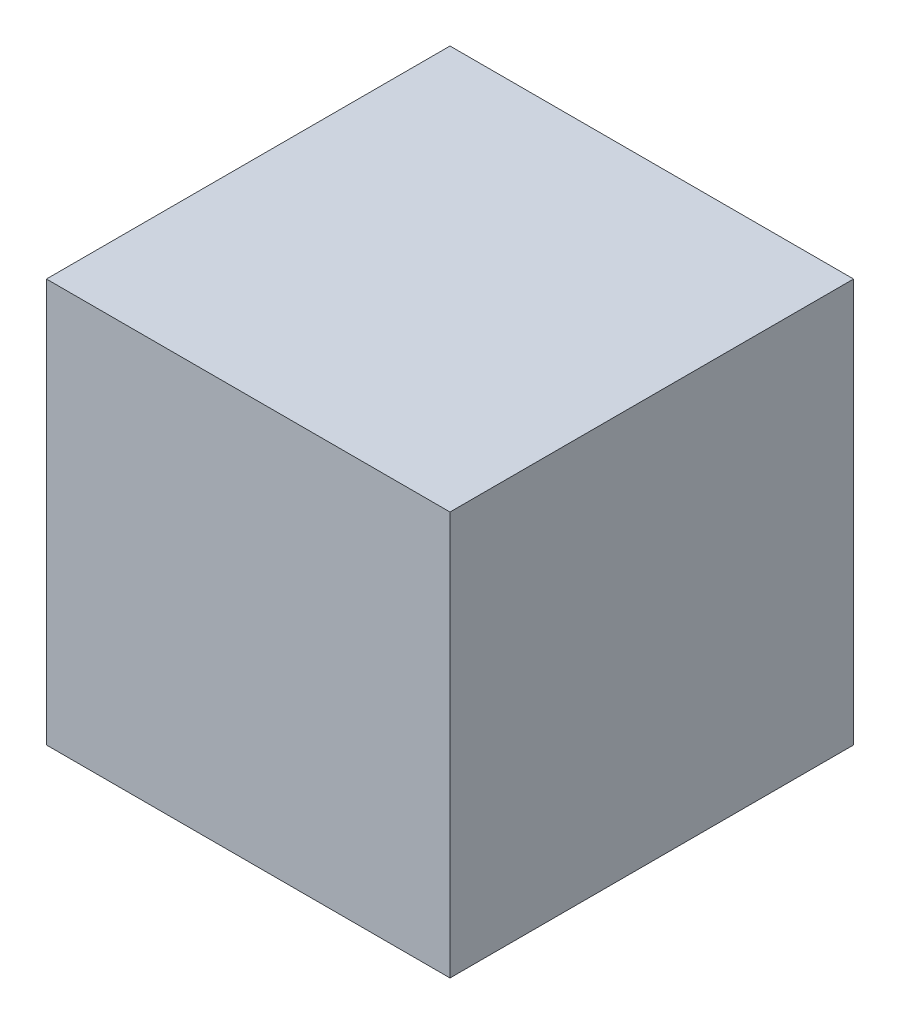
from build123d import *

# Parameters (mm, degrees)
SKETCH1_W           = 254
SKETCH1_H           = 254
BOSS_EXTRUDE1_DEPTH = 127


with BuildPart() as part:
    # Sketch1 → Boss-Extrude1 (new body, symmetric)
    with BuildSketch(Plane.XY):
        Rectangle(SKETCH1_W, SKETCH1_H)
    extrude(amount=BOSS_EXTRUDE1_DEPTH, both=True)


solid = part.part
